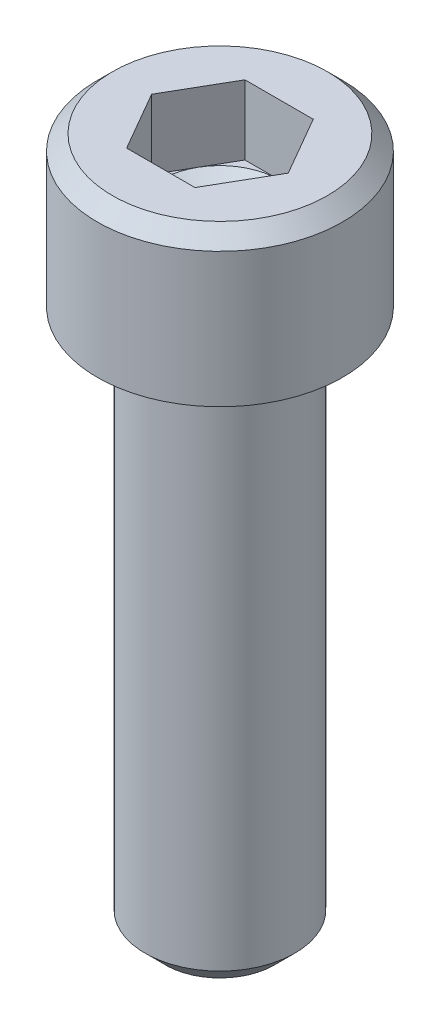
from build123d import *

# Parameters (mm, degrees)
CUT_EXTRUDE1_DEPTH = 1.6256


with BuildPart() as part:
    # Sketch5 → Revolve2 (revolve)
    with BuildSketch(Plane.XY):
        with BuildLine():
            Line((0, 1.080374022), (0, -12.7))
            Line((0, -12.7), (1.28016, -12.7))
            Line((1.28016, -12.7), (1.7526, -12.22756))
            Line((1.7526, -12.22756), (1.7526, -0.254))
            ThreePointArc((1.7526, -0.254), (1.826994878, -0.074394878), (2.0066, 0))
            Line((2.0066, 0), (2.8702, 0))
            Line((2.8702, 0), (2.8702, 3.1496))
            Line((2.8702, 3.1496), (2.5146, 3.5052))
            Line((2.5146, 3.5052), (1.3843, 3.5052))
            Line((1.3843, 3.5052), (1.3843, 1.8796))
            Line((1.3843, 1.8796), (0, 1.080374022))
        make_face()
    revolve(axis=Axis((0, 3.5052, 0), (0, 1, 0)))

    # Sketch3 → Cut-Extrude1 (cut)
    with BuildSketch(Plane(origin=(0, 3.5052, 0), x_dir=(1, 0, 0), z_dir=(0, 1, 0))):
        Polygon((-1.598451955, 0), (-0.799225978, -1.3843), (0.799225978, -1.3843), (1.598451955, 0), (0.799225978, 1.3843), (-0.799225978, 1.3843), align=None)
    extrude(amount=-CUT_EXTRUDE1_DEPTH, mode=Mode.SUBTRACT)


solid = part.part
